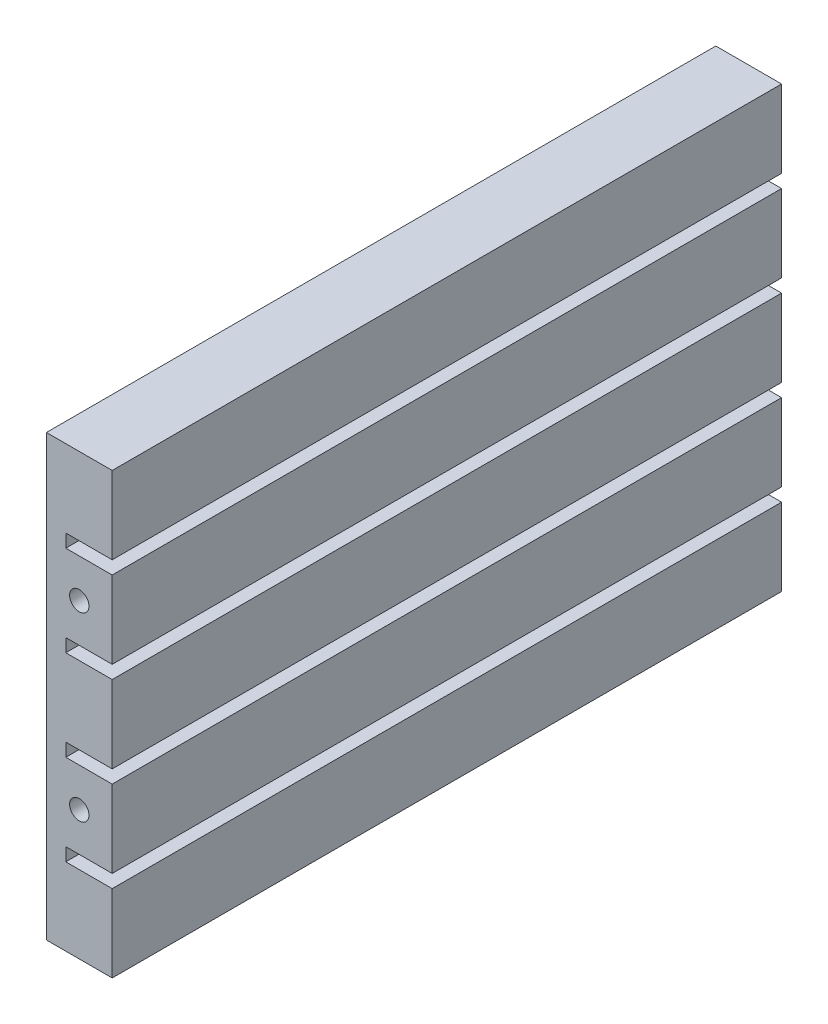
from build123d import *

# Parameters (mm, degrees)
BOSS_EXTRUDE1_DEPTH            = 86.5
M3X0_5_TAPPED_HOLE2_AT_2_COUNT = 2
M3X0_5_TAPPED_HOLE2_AT_2_PITCH = 23.4
M3X0_5_TAPPED_HOLE1_AT_2_COUNT = 2
M3X0_5_TAPPED_HOLE1_AT_2_PITCH = 46.8


with BuildPart() as part:
    # Sketch1 → Boss-Extrude1 (new body)
    with BuildSketch(Plane.XY):
        Polygon((0, 0), (0, 56.8), (8.5, 56.8), (8.5, 46.8), (2.5, 46.8), (2.5, 45.1), (8.5, 45.1), (8.5, 35.1), (2.5, 35.1), (2.5, 33.4), (8.5, 33.4), (8.5, 23.4), (2.5, 23.4), (2.5, 21.7), (8.5, 21.7), (8.5, 11.7), (2.5, 11.7), (2.5, 10), (8.5, 10), (8.5, 0), align=None)
    extrude(amount=BOSS_EXTRUDE1_DEPTH)

    # Sketch4 → M3x0.5 Tapped Hole2 (revolve, cut)
    with BuildSketch(Plane(origin=(4.25, 40.1, 86.5), x_dir=(0, -1, 0), z_dir=(1, 0, 0))):
        Polygon((0, 0), (0, 5.751075774), (1.25, 5), (1.25, 0), align=None)
    m3x0_5_tapped_hole2 = revolve(axis=Axis((4.25, 40.1, 92.85), (0, 0, -1)), mode=Mode.SUBTRACT)

    # M3x0.5 Tapped Hole2 at 2: M3x0.5 Tapped Hole2 ×2
    with Locations(*[(0, -i * M3X0_5_TAPPED_HOLE2_AT_2_PITCH, 0) for i in range(1, M3X0_5_TAPPED_HOLE2_AT_2_COUNT)]):
        add(m3x0_5_tapped_hole2, mode=Mode.SUBTRACT)

    # Mirror1: M3x0.5 Tapped Hole2 across plane
    add(m3x0_5_tapped_hole2.mirror(Plane.XY.offset(43.25)), mode=Mode.SUBTRACT)

    # Mirror1 copy 1 sketch → Mirror1 copy 1 (revolve, cut)
    with BuildSketch(Plane(origin=(4.25, 16.7, 0), x_dir=(0, -1, 0), z_dir=(1, 0, 0))):
        Polygon((0, 0), (0, -5.751075774), (1.25, -5), (1.25, 0), align=None)
    revolve(axis=Axis((4.25, 16.7, -6.35), (0, 0, -1)), mode=Mode.SUBTRACT)

    # Sketch11 → M3x0.5 Tapped Hole1 (revolve, cut)
    with BuildSketch(Plane(origin=(0, 5, 8.25), x_dir=(0, 0, 1), z_dir=(0, 1, 0))):
        Polygon((0, 0), (0, 5.751075774), (1.25, 5), (1.25, 0), align=None)
    m3x0_5_tapped_hole1 = revolve(axis=Axis((-6.35, 5, 8.25), (1, 0, 0)), mode=Mode.SUBTRACT)

    # M3x0.5 Tapped Hole1 at 2: M3x0.5 Tapped Hole1 ×2
    with Locations(*[(0, i * M3X0_5_TAPPED_HOLE1_AT_2_PITCH, 0) for i in range(1, M3X0_5_TAPPED_HOLE1_AT_2_COUNT)]):
        add(m3x0_5_tapped_hole1, mode=Mode.SUBTRACT)

    # Mirror2: M3x0.5 Tapped Hole1 across plane
    add(m3x0_5_tapped_hole1.mirror(Plane(origin=(0, 0, 43.25), x_dir=(1, 0, 0), z_dir=(0, 0, -1))), mode=Mode.SUBTRACT)

    # Mirror2 copy 1 sketch → Mirror2 copy 1 (revolve, cut)
    with BuildSketch(Plane(origin=(0, 51.8, 78.25), x_dir=(0, 0, -1), z_dir=(0, 1, 0))):
        Polygon((0, 0), (0, -5.751075774), (1.25, -5), (1.25, 0), align=None)
    revolve(axis=Axis((-6.35, 51.8, 78.25), (-1, 0, 0)), mode=Mode.SUBTRACT)


solid = part.part
